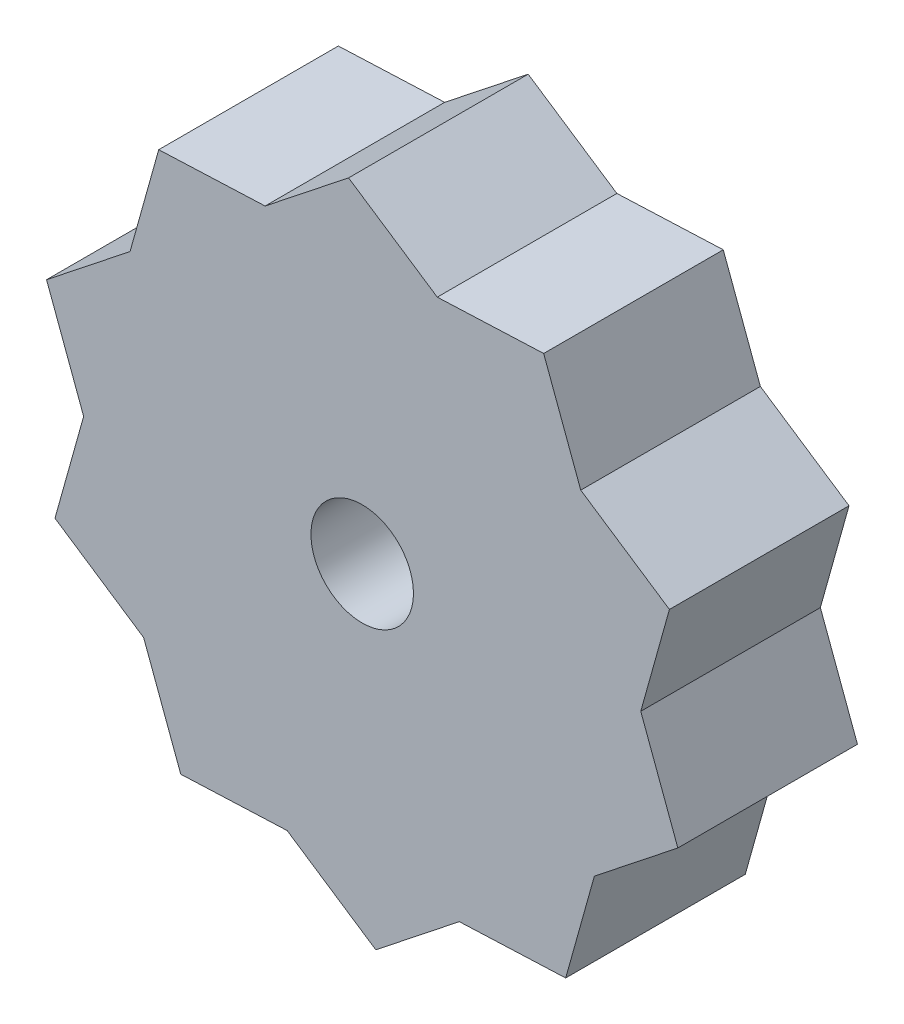
from build123d import *

# Parameters (mm, degrees)
BOSS_EXTRUDE1_DEPTH = 5.08
SKETCH2_3_R         = 1.45
CUT_EXTRUDE1_DEPTH  = 14.831568379


with BuildPart() as part:
    # Sketch2 → Boss-Extrude1 (new body)
    with BuildSketch(Plane.XY):
        Polygon((6.181876589, 4.896209998), (5.132895747, 7.719827316), (2.123323189, 7.594732987), (-0.385000757, 9.262511914), (-2.7462675, 7.392326111), (-5.755840057, 7.267231781), (-6.566877347, 4.366301916), (-8.928144089, 2.496116113), (-7.879163247, -0.327501205), (-8.690200536, -3.228431071), (-6.181876589, -4.896209998), (-5.132895747, -7.719827316), (-2.123323189, -7.594732987), (0.385000757, -9.262511914), (2.7462675, -7.392326111), (5.755840057, -7.267231781), (6.566877347, -4.366301916), (8.928144089, -2.496116113), (7.879163247, 0.327501205), (8.690200536, 3.228431071), align=None)
    extrude(amount=BOSS_EXTRUDE1_DEPTH)

    # Sketch2_3 → Cut-Extrude1 (cut, through all)
    with BuildSketch(Plane.XY):
        Circle(SKETCH2_3_R)
    extrude(amount=CUT_EXTRUDE1_DEPTH, mode=Mode.SUBTRACT)


solid = part.part
